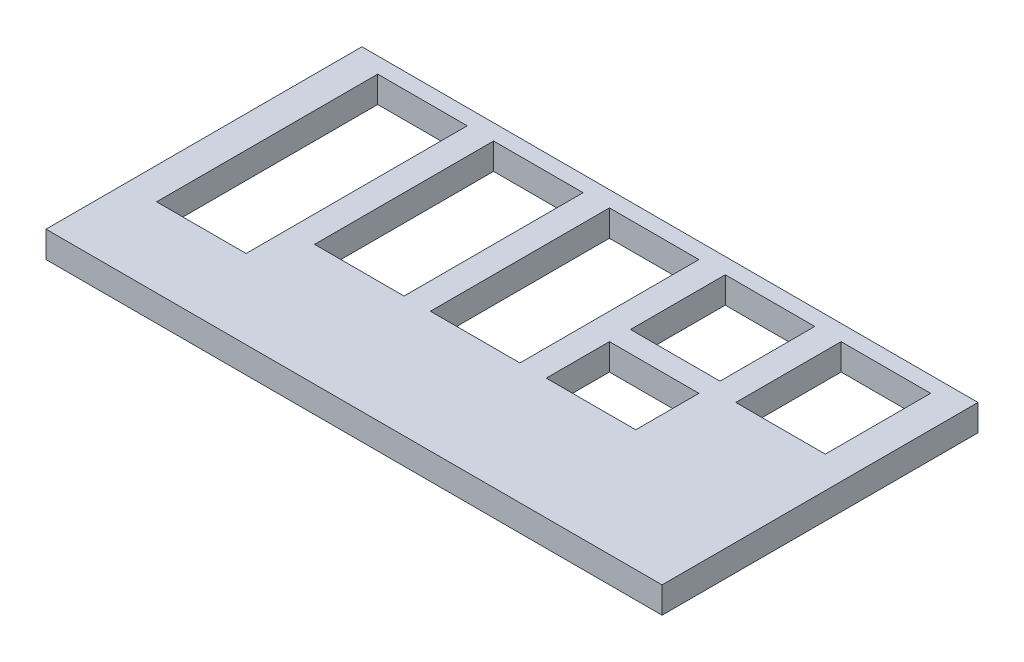
from build123d import *

# Parameters (mm, degrees)
SKETCH1_W           = 117
SKETCH1_H           = 60
SKETCH1_W_2         = 17
SKETCH1_H_2         = 18
SKETCH1_H_3         = 42
SKETCH1_H_4         = 34
SKETCH1_H_5         = 20
SKETCH1_H_6         = 12
BOSS_EXTRUDE1_DEPTH = 5


with BuildPart() as part:
    # Sketch1 → Boss-Extrude1 (new body)
    with BuildSketch(Plane(origin=(0, 0, 0), x_dir=(1, 0, 0), z_dir=(0, 1, 0))):
        Rectangle(SKETCH1_W, SKETCH1_H)
        with Locations((22, 18)):
            Rectangle(SKETCH1_W_2, SKETCH1_H_2, mode=Mode.SUBTRACT)
        with Locations((-44, 6)):
            Rectangle(SKETCH1_W_2, SKETCH1_H_3, mode=Mode.SUBTRACT)
        with Locations((-22, 10)):
            Rectangle(SKETCH1_W_2, SKETCH1_H_4, mode=Mode.SUBTRACT)
        with Locations((0, 10)):
            Rectangle(SKETCH1_W_2, SKETCH1_H_4, mode=Mode.SUBTRACT)
        with Locations((44, 17)):
            Rectangle(SKETCH1_W_2, SKETCH1_H_5, mode=Mode.SUBTRACT)
        with Locations((22, -1)):
            Rectangle(SKETCH1_W_2, SKETCH1_H_6, mode=Mode.SUBTRACT)
    extrude(amount=BOSS_EXTRUDE1_DEPTH)


solid = part.part
